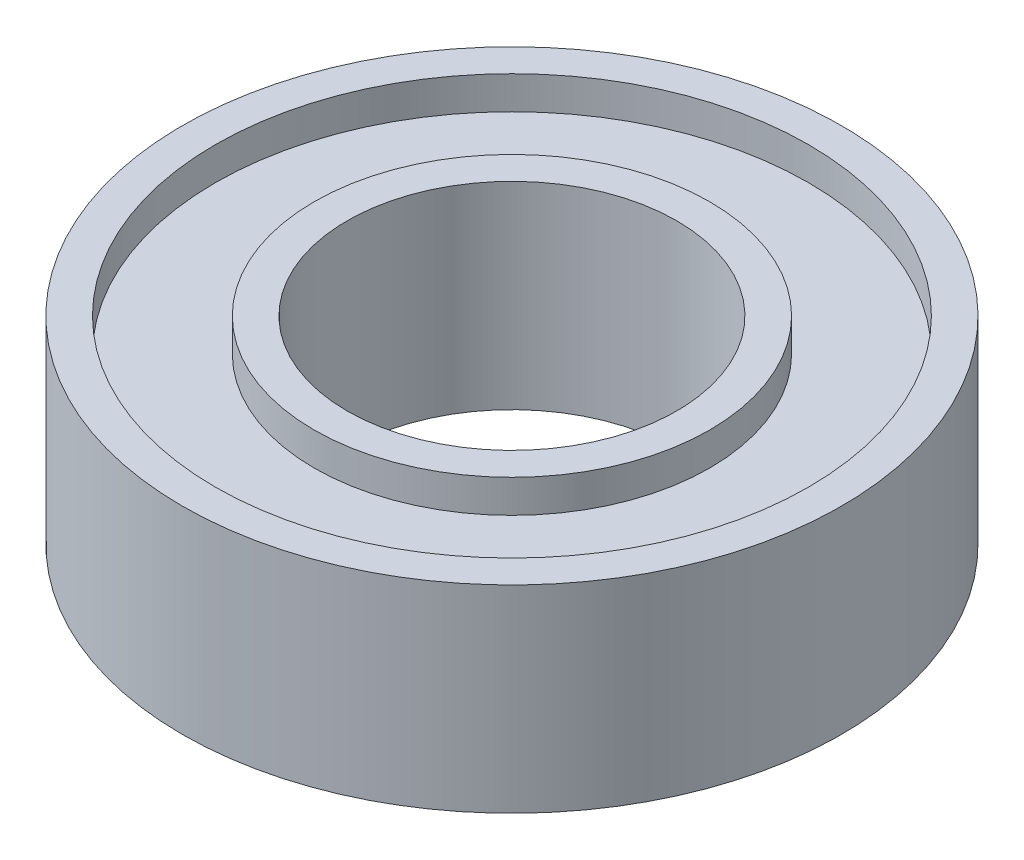
from build123d import *

# Parameters (mm, degrees)
CROQUIS2_R              = 5
CROQUIS2_R_2            = 2.5
SALIENTE_EXTRUIR1_DEPTH = 3
CROQUIS3_R              = 4.5
CROQUIS3_R_2            = 3
CORTAR_EXTRUIR1_DEPTH   = 0.5


with BuildPart() as part:
    # Croquis2 → Saliente-Extruir1 (new body)
    with BuildSketch(Plane(origin=(0, 0, 0), x_dir=(1, 0, 0), z_dir=(0, 1, 0))):
        Circle(CROQUIS2_R)
        Circle(CROQUIS2_R_2, mode=Mode.SUBTRACT)
    extrude(amount=SALIENTE_EXTRUIR1_DEPTH)

    # Croquis3 → Cortar-Extruir1 (cut)
    with BuildSketch(Plane(origin=(0, 3, 0), x_dir=(1, 0, 0), z_dir=(0, 1, 0))):
        Circle(CROQUIS3_R)
        Circle(CROQUIS3_R_2, mode=Mode.SUBTRACT)
    cortar_extruir1 = extrude(amount=-CORTAR_EXTRUIR1_DEPTH, mode=Mode.SUBTRACT)

    # Simetría1: Cortar-Extruir1 across plane
    add(cortar_extruir1.mirror(Plane.ZX.offset(1.5)), mode=Mode.SUBTRACT)


solid = part.part
